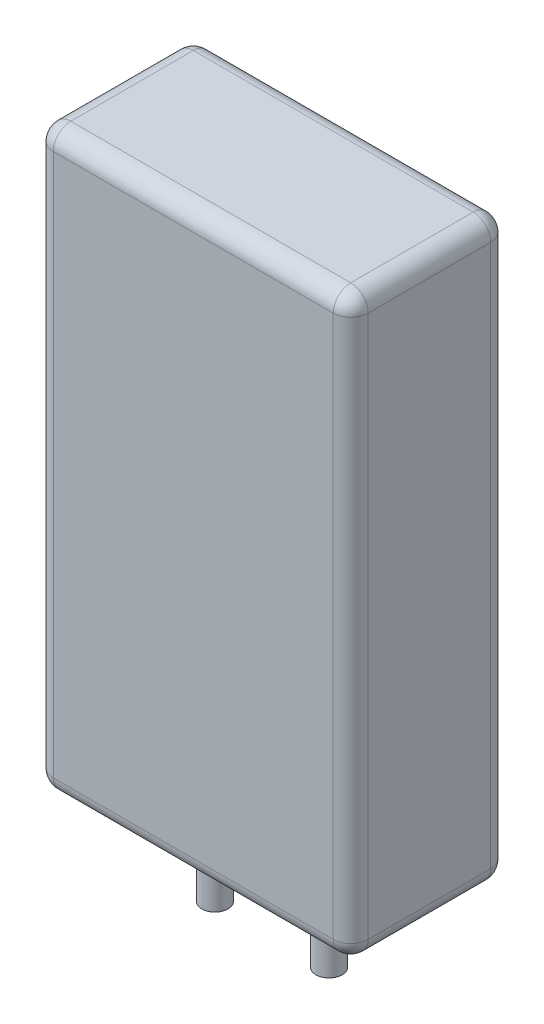
from build123d import *

# Parameters (mm, degrees)
ESQUISSE1_W        = 36
ESQUISSE1_H        = 66
BOSS_EXTRU_1_DEPTH = 18
CONG_1_R           = 2
ESQUISSE2_R        = 1.5
BOSS_EXTRU_2_DEPTH = 10
ESQUISSE3_R        = 2
ESQUISSE3_R_2      = 1.5
BOSS_EXTRU_3_DEPTH = 5


with BuildPart() as part:
    # Esquisse1 → Boss.-Extru.1 (new body)
    with BuildSketch(Plane.XY):
        with Locations((-0.486264987, 10.73553719)):
            Rectangle(ESQUISSE1_W, ESQUISSE1_H)
    extrude(amount=BOSS_EXTRU_1_DEPTH)

    # Congé1
    cong_1_edges = [part.edges().sort_by_distance(p)[0] for p in [
        (17.513735013, 10.73553719, 18),
        (-0.486264987, 43.73553719, 18),
        (-18.486264987, 10.73553719, 18),
        (-0.486264987, 43.73553719, 0),
        (17.513735013, 10.73553719, 0),
        (-0.486264987, -22.26446281, 0),
        (-18.486264987, 10.73553719, 0),
        (-0.486264987, -22.26446281, 18),
        (-18.486264987, 43.73553719, 9),
        (17.513735013, 43.73553719, 9),
        (17.513735013, -22.26446281, 9),
        (-18.486264987, -22.26446281, 9),
    ]]
    fillet(cong_1_edges, radius=CONG_1_R)

    # Esquisse2 → Boss.-Extru.2 (add)
    with BuildSketch(Plane.XZ.offset(22.26446281)):
        with Locations((-7.00866392, 9)):
            Circle(ESQUISSE2_R)
        with Locations((6.036133945, 9)):
            Circle(ESQUISSE2_R)
    extrude(amount=BOSS_EXTRU_2_DEPTH)

    # Esquisse3 → Boss.-Extru.3 (add)
    with BuildSketch(Plane.XZ.offset(22.26446281)):
        with Locations((-7.00866392, 9)):
            Circle(ESQUISSE3_R)
        with Locations((-7.00866392, 9)):
            Circle(ESQUISSE3_R_2, mode=Mode.SUBTRACT)
        with Locations((6.036133945, 9)):
            Circle(ESQUISSE3_R)
        with Locations((6.036133945, 9)):
            Circle(ESQUISSE3_R_2, mode=Mode.SUBTRACT)
    extrude(amount=BOSS_EXTRU_3_DEPTH)


solid = part.part
